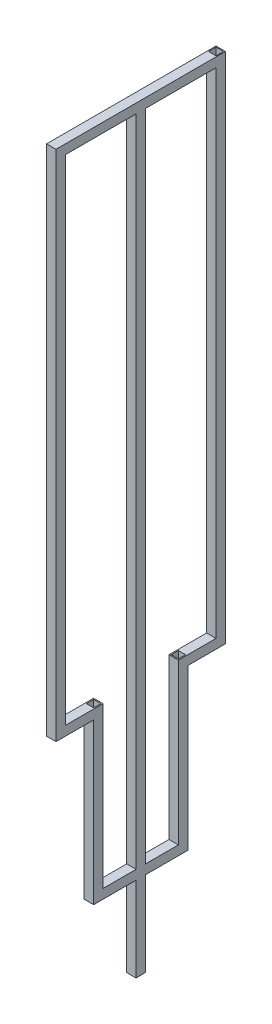
from build123d import *

# Parameters (mm, degrees)
SKETCH1_W           = 2
SKETCH1_H           = 2
SKETCH1_W_2         = 1.6
SKETCH1_H_2         = 1.6
BOSS_EXTRUDE1_DEPTH = 109
SKETCH2_W           = 2
SKETCH2_H           = 2
SKETCH2_W_2         = 1.6
SKETCH2_H_2         = 1.6
BOSS_EXTRUDE2_DEPTH = 34
SKETCH3_W           = 2
SKETCH3_H           = 2
SKETCH3_W_2         = 1.6
SKETCH3_H_2         = 1.6
BOSS_EXTRUDE3_DEPTH = 6
SKETCH7_W           = 2
SKETCH7_H           = 2
SKETCH7_W_2         = 1.54
SKETCH7_H_2         = 1.54
BOSS_EXTRUDE4_DEPTH = 36
BOSS_EXTRUDE5_REACH = 28
SKETCH8_W           = 2
SKETCH8_H           = 2
SKETCH8_W_2         = 1.6
SKETCH8_H_2         = 1.6
SCALE2_SCALE        = 10
BOSS_EXTRUDE6_REACH = 1412
SKETCH9_W           = 20
SKETCH9_H           = 20
SKETCH9_W_2         = 16
SKETCH9_H_2         = 16
SKETCH10_W          = 20
SKETCH10_H          = 20
SKETCH10_W_2        = 16
SKETCH10_H_2        = 16
BOSS_EXTRUDE7_DEPTH = 179.85


with BuildPart() as part:
    # Sketch1 → Boss-Extrude1 (new body)
    with BuildSketch(Plane(origin=(0, 0, 0), x_dir=(1, 0, 0), z_dir=(0, 1, 0))):
        Rectangle(SKETCH1_W, SKETCH1_H)
        Rectangle(SKETCH1_W_2, SKETCH1_H_2, mode=Mode.SUBTRACT)
    boss_extrude1 = extrude(amount=BOSS_EXTRUDE1_DEPTH)

    # Sketch2 → Boss-Extrude2 (add)
    with BuildSketch(Plane.XY.offset(1)):
        with Locations((0, 108)):
            Rectangle(SKETCH2_W, SKETCH2_H)
        with Locations((0, 108)):
            Rectangle(SKETCH2_W_2, SKETCH2_H_2, mode=Mode.SUBTRACT)
    extrude(amount=BOSS_EXTRUDE2_DEPTH)

    # Mirror1: Boss-Extrude1 across plane
    add(boss_extrude1.mirror(Plane.XY.offset(17)))

    # Sketch3 → Boss-Extrude3 (add)
    with BuildSketch(Plane.XY.offset(1)):
        with Locations((0, 1)):
            Rectangle(SKETCH3_W, SKETCH3_H)
        with Locations((0, 1)):
            Rectangle(SKETCH3_W_2, SKETCH3_H_2, mode=Mode.SUBTRACT)
    boss_extrude3 = extrude(amount=BOSS_EXTRUDE3_DEPTH)

    # Sketch7 → Boss-Extrude4 (add)
    with BuildSketch(Plane(origin=(0, 2, 0), x_dir=(1, 0, 0), z_dir=(0, 1, 0))):
        with Locations((0, -8)):
            Rectangle(SKETCH7_W, SKETCH7_H)
        with Locations((0, -8)):
            Rectangle(SKETCH7_W_2, SKETCH7_H_2, mode=Mode.SUBTRACT)
    boss_extrude4 = extrude(amount=-BOSS_EXTRUDE4_DEPTH)

    # Mirror2: Boss-Extrude3, Boss-Extrude4 across plane
    add(boss_extrude3.mirror(Plane.XY.offset(17)))
    add(boss_extrude4.mirror(Plane.XY.offset(17)))

    # Sketch8 → Boss-Extrude5 (add, up to next)
    with BuildSketch(Plane(origin=(0, 0, 25), x_dir=(-1, 0, 0), z_dir=(0, 0, -1)), mode=Mode.PRIVATE) as boss_extrude5_sk1:
        with Locations((0, -33)):
            Rectangle(SKETCH8_W, SKETCH8_H)
        with Locations((0, -33)):
            Rectangle(SKETCH8_W_2, SKETCH8_H_2, mode=Mode.SUBTRACT)
    boss_extrude5_tool1 = extrude(boss_extrude5_sk1.sketch, amount=BOSS_EXTRUDE5_REACH, mode=Mode.PRIVATE) - part.part
    add(boss_extrude5_tool1.solids().sort_by_distance((0, -32.028284, 25))[0])


with BuildPart() as part_1:
    # Scale2: scaled about (0, 0, 0)
    add(part.part.scale(SCALE2_SCALE))

    # Sketch9 → Boss-Extrude6 (add, up to next)
    with BuildSketch(Plane.XZ.offset(-1070), mode=Mode.PRIVATE) as boss_extrude6_sk1:
        with Locations((0, 169.738105544)):
            Rectangle(SKETCH9_W, SKETCH9_H)
        with Locations((0, 169.738105544)):
            Rectangle(SKETCH9_W_2, SKETCH9_H_2, mode=Mode.SUBTRACT)
    boss_extrude6_tool1 = extrude(boss_extrude6_sk1.sketch, amount=BOSS_EXTRUDE6_REACH, mode=Mode.PRIVATE) - part_1.part
    add(boss_extrude6_tool1.solids().sort_by_distance((0, 1070, 179.455263))[0])

    # Sketch10 → Boss-Extrude7 (add)
    with BuildSketch(Plane.XZ.offset(340)):
        with Locations((0, 170)):
            Rectangle(SKETCH10_W, SKETCH10_H)
        with Locations((0, 170)):
            Rectangle(SKETCH10_W_2, SKETCH10_H_2, mode=Mode.SUBTRACT)
    extrude(amount=BOSS_EXTRUDE7_DEPTH)


solid = part_1.part
